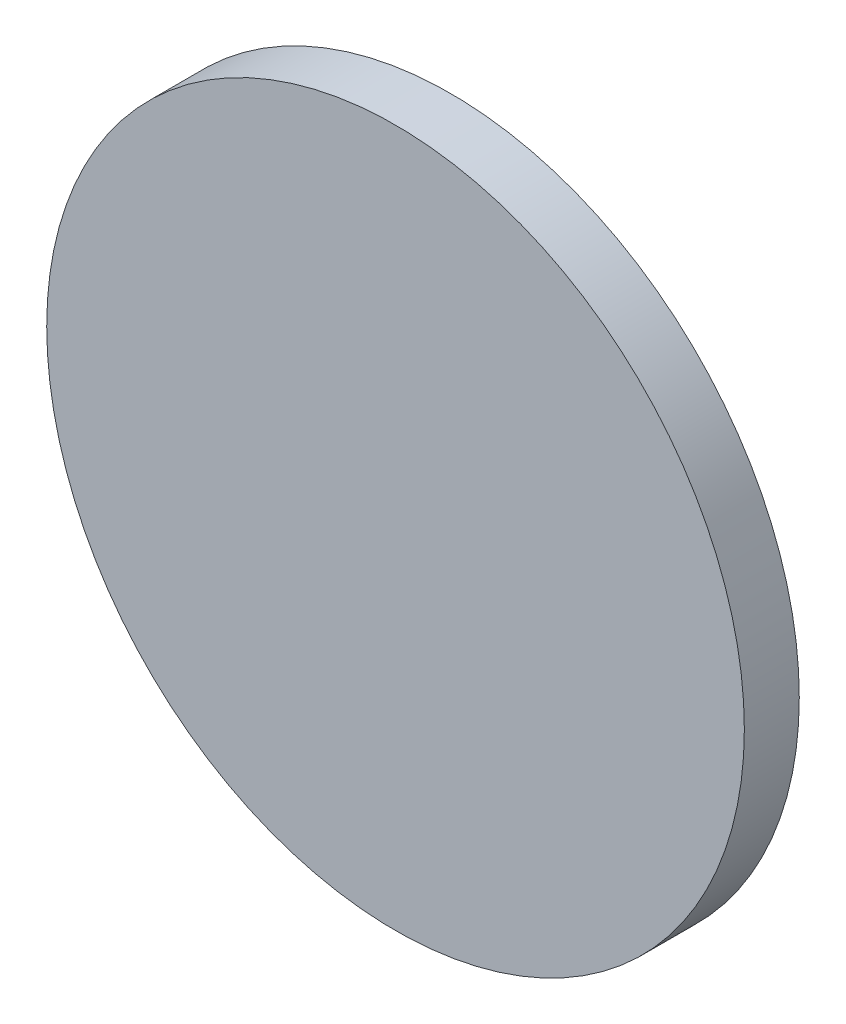
from build123d import *

# Parameters (mm, degrees)
SKETCH_1_R      = 25.4
EXTRUDE_1_DEPTH = 4


with BuildPart() as part:
    # 草图1 → 凸台-拉伸1 (new body)
    with BuildSketch(Plane.XY):
        Circle(SKETCH_1_R)
    extrude(amount=EXTRUDE_1_DEPTH)


solid = part.part
